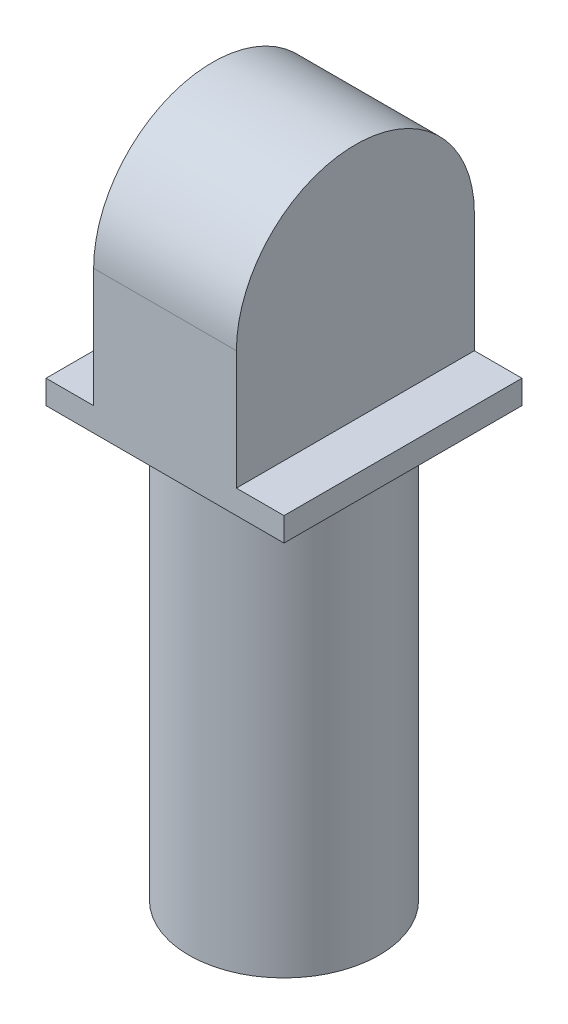
from build123d import *

# Parameters (mm, degrees)
SKETCH_1_W          = 10
SKETCH_1_H          = 10
EXTRUDE_1_DEPTH     = 11
SKETCH_2_R          = 4
EXTRUDE_2_DEPTH     = 18
SKETCH_3_W          = 2
SKETCH_3_H          = 10
CUT_EXTRUDE_1_DEPTH = 46
CUT_EXTRUDE_2_DEPTH = 46


with BuildPart() as part:
    # 草图1 → 凸台-拉伸1 (new body)
    with BuildSketch(Plane(origin=(0, 0, 0), x_dir=(1, 0, 0), z_dir=(0, 1, 0))):
        Rectangle(SKETCH_1_W, SKETCH_1_H)
    extrude(amount=EXTRUDE_1_DEPTH)

    # 草图2 → 凸台-拉伸2 (add)
    with BuildSketch(Plane.XZ):
        Circle(SKETCH_2_R)
    extrude(amount=EXTRUDE_2_DEPTH)

    # 草图3 → 切除-拉伸1 (cut)
    with BuildSketch(Plane.XY.offset(5)):
        with Locations((-4, 6)):
            Rectangle(SKETCH_3_W, SKETCH_3_H)
        with Locations((4, 6)):
            Rectangle(SKETCH_3_W, SKETCH_3_H)
    extrude(amount=-CUT_EXTRUDE_1_DEPTH, mode=Mode.SUBTRACT)

    # 草图4 → 切除-拉伸2 (cut)
    with BuildSketch(Plane(origin=(3, 0, 0), x_dir=(0, 0, -1), z_dir=(1, 0, 0))):
        with BuildLine():
            Line((-5, 6), (-5, 15.436246411))
            Line((-5, 15.436246411), (5, 15.436246411))
            Line((5, 15.436246411), (5, 6))
            ThreePointArc((5, 6), (0, 11), (-5, 6))
        make_face()
    extrude(amount=-CUT_EXTRUDE_2_DEPTH, mode=Mode.SUBTRACT)


solid = part.part
